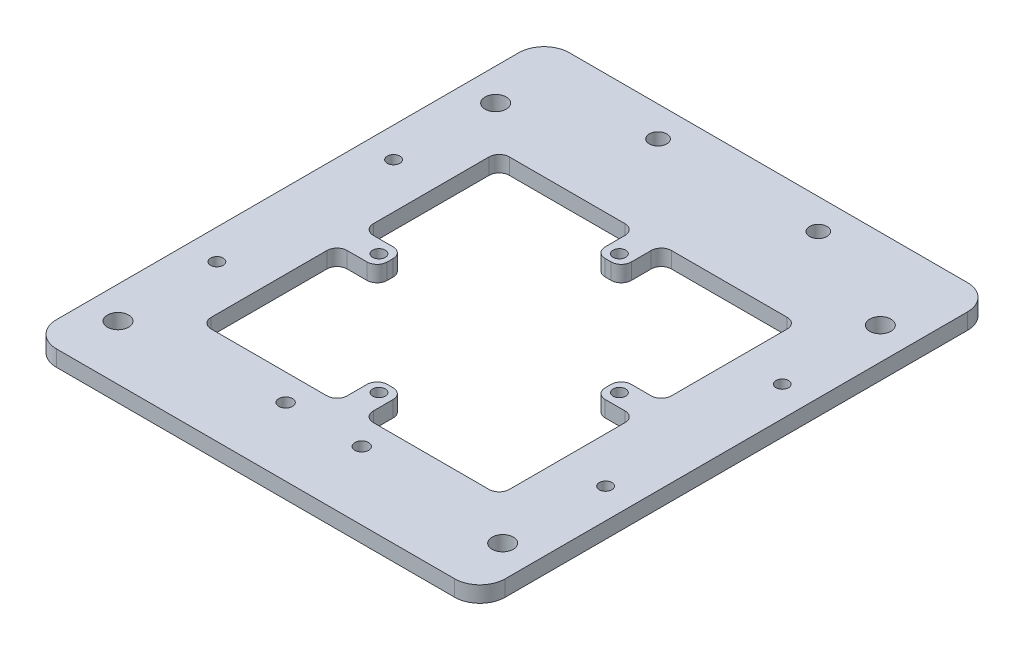
from build123d import *

# Parameters (mm, degrees)
ALUMINUM_PLATE_DEPTH            = 3.175
LPATTERN1_COUNT                 = 2
LPATTERN1_PITCH                 = 35
LPATTERN1_COUNT_DIR2            = 2
LPATTERN1_PITCH_DIR2            = 77
CIRPATTERN1_COUNT               = 4
TAP_DRILL_FOR_M5X0_8_TAP1_D     = 4.2
TAP_DRILL_FOR_M5X0_8_TAP1_DEPTH = 25.4
TAP_DRILL_FOR_M5X0_8_TAP1_TIP   = 1.2618073
TAP_DRILL_FOR_8_32_TAP1_D       = 3.4544
TAP_DRILL_FOR_8_32_TAP1_DEPTH   = 12.7
TAP_DRILL_FOR_8_32_TAP1_TIP     = 1.037806461
CUT_EXTRUDE1_REACH              = 96.743
CIRPATTERN3_COUNT               = 4
TAP_DRILL_FOR_6_32_TAP1_D       = 2.7051
TAP_DRILL_FOR_6_32_TAP1_DEPTH   = 12.7
TAP_DRILL_FOR_6_32_TAP1_TIP     = 0.81269403


with BuildPart() as part:
    # Sketch2 → Aluminum plate (new body)
    with BuildSketch(Plane(origin=(0, 0, 0), x_dir=(1, 0, 0), z_dir=(0, 1, 0))):
        with BuildLine():
            Line((58.024404898, -30.931736602), (-20.876528813, -30.930973959))
            ThreePointArc((-20.876528813, -30.930973959), (-24.412048563, -29.466473691), (-25.876480484, -25.93092563))
            Line((-25.876480484, -25.93092563), (-25.875595093, 65.669074365))
            ThreePointArc((-25.875595093, 65.669074365), (-24.411094826, 69.204594116), (-20.875546764, 70.669026036))
            Line((-20.875546764, 70.669026036), (58.024501561, 70.668263401))
            ThreePointArc((58.024501561, 70.668263401), (61.560004224, 69.20378022), (63.024453231, 65.668263401))
            Line((63.024453231, 65.668263401), (63.024453227, -25.931736603))
            ThreePointArc((63.024453227, -25.931736603), (61.559970046, -29.467287596), (58.024404898, -30.931736602))
        make_face()
        Polygon((40.164453228, -4.2611466), (-3.015546772, -4.261146598), (-3.01554677, 38.918853402), (40.16445323, 38.9188534), align=None, mode=Mode.SUBTRACT)
    extrude(amount=ALUMINUM_PLATE_DEPTH)

    # Sketch12 → Tap Drill for M3x0.5 Tap1 (revolve, cut)
    with BuildSketch(Plane(origin=(-19.925892409, 3.175, -34.909619628), x_dir=(0, 0, 1), z_dir=(1, 0, 0))):
        Polygon((0, 0), (0, 26.151075774), (1.25, 25.4), (1.25, 0), align=None)
    tap_drill_for_m3x0_5_tap1 = revolve(axis=Axis((-19.925892409, 9.525, -34.909619628), (0, -1, 0)), mode=Mode.SUBTRACT)

    # LPattern1: Tap Drill for M3x0.5 Tap1 2 × 2
    with Locations(*[(j * LPATTERN1_PITCH_DIR2, 0, i * LPATTERN1_PITCH) for i in range(LPATTERN1_COUNT) for j in range(LPATTERN1_COUNT_DIR2) if (i, j) != (0, 0)]):
        add(tap_drill_for_m3x0_5_tap1, mode=Mode.SUBTRACT)

    # Sketch14 → Tap Drill for M3x0.5 Tap2 (revolve, cut)
    with BuildSketch(Plane(origin=(42.384453228, 3.175, -17.329161252), x_dir=(0, 0, 1), z_dir=(1, 0, 0))):
        Polygon((0, 0), (0, 26.151075774), (1.25, 25.4), (1.25, 0), align=None)
    tap_drill_for_m3x0_5_tap2 = revolve(axis=Axis((42.384453228, 9.525, -17.329161252), (0, -1, 0)), mode=Mode.SUBTRACT)

    # CirPattern1: Tap Drill for M3x0.5 Tap2 ×4 about axis
    cirpattern1_axis = Axis((18.574453229, 62.671328425, -17.328853401), (0, -1, 0))
    for i in range(1, CIRPATTERN1_COUNT):
        add(tap_drill_for_m3x0_5_tap2.rotate(cirpattern1_axis, i * 360 / CIRPATTERN1_COUNT), mode=Mode.SUBTRACT)

    # Tap Drill for M5x0.8 Tap1
    with Locations(Plane.XZ):
        with Locations((-19.525700823, -54.730512991), (56.674299173, -54.729776455), (56.67357614, 20.073223545), (-19.526423857, 20.072487009)):
            Hole(TAP_DRILL_FOR_M5X0_8_TAP1_D / 2, depth=TAP_DRILL_FOR_M5X0_8_TAP1_DEPTH)
            with Locations((0, 0, -(TAP_DRILL_FOR_M5X0_8_TAP1_DEPTH + TAP_DRILL_FOR_M5X0_8_TAP1_TIP / 2))):  # 118° drill point
                Cone(0, TAP_DRILL_FOR_M5X0_8_TAP1_D / 2, TAP_DRILL_FOR_M5X0_8_TAP1_TIP, mode=Mode.SUBTRACT)

    # Tap Drill for _8-32 Tap1
    with Locations(Plane(origin=(0, 3.175, 0), x_dir=(-1, 0, 0), z_dir=(0, 1, 0))):
        with Locations((-2.699395239, -64.668798164), (-34.449395238, -64.668491274)):
            Hole(TAP_DRILL_FOR_8_32_TAP1_D / 2, depth=TAP_DRILL_FOR_8_32_TAP1_DEPTH)
            with Locations((0, 0, -(TAP_DRILL_FOR_8_32_TAP1_DEPTH + TAP_DRILL_FOR_8_32_TAP1_TIP / 2))):  # 118° drill point
                Cone(0, TAP_DRILL_FOR_8_32_TAP1_D / 2, TAP_DRILL_FOR_8_32_TAP1_TIP, mode=Mode.SUBTRACT)

    # Sketch24 → Cut-Extrude1 (cut, up to next)
    with BuildSketch(Plane(origin=(0, 3.175, 0), x_dir=(1, 0, 0), z_dir=(0, 1, 0)), mode=Mode.PRIVATE) as cut_extrude1_sk1:
        with BuildLine():
            Line((21.16445323, 40.9188534), (21.16445323, 44.8563534))
            ThreePointArc((21.16445323, 44.8563534), (21.750239668, 46.270566962), (23.16445323, 46.8563534))
            Line((23.16445323, 46.8563534), (46.101953228, 46.8563534))
            ThreePointArc((46.101953228, 46.8563534), (47.516166791, 46.270566962), (48.101953228, 44.8563534))
            Line((48.101953228, 44.8563534), (48.101953228, 21.9188534))
            ThreePointArc((48.101953228, 21.9188534), (47.516166791, 20.504639837), (46.101953228, 19.9188534))
            Line((46.101953228, 19.9188534), (42.164453228, 19.9188534))
            ThreePointArc((42.164453228, 19.9188534), (40.750239666, 19.333066962), (40.164453228, 17.9188534))
            Line((40.164453228, 17.9188534), (40.164453228, 17.3288534))
            Line((40.164453228, 17.3288534), (18.57445323, 38.9188534))
            Line((18.57445323, 38.9188534), (19.16445323, 38.9188534))
            ThreePointArc((19.16445323, 38.9188534), (20.578666793, 39.504639837), (21.16445323, 40.9188534))
        make_face()
    cut_extrude1_tool1 = extrude(cut_extrude1_sk1.sketch, amount=-CUT_EXTRUDE1_REACH, mode=Mode.PRIVATE) & part.part
    cut_extrude1 = cut_extrude1_tool1.solids().sort_by_distance((36.353241, 3.175, -35.107642))[0]
    add(cut_extrude1, mode=Mode.SUBTRACT)

    # CirPattern3: Cut-Extrude1 ×4 about axis
    cirpattern3_axis = Axis((18.574453229, 62.671328425, -17.328853401), (0, -1, 0))
    for i in range(1, CIRPATTERN3_COUNT):
        add(cut_extrude1.rotate(cirpattern3_axis, i * 360 / CIRPATTERN3_COUNT), mode=Mode.SUBTRACT)

    # Tap Drill for _6-32 Tap1
    with Locations(Plane(origin=(0, 3.175, 0), x_dir=(-1, 0, 0), z_dir=(0, 1, 0))):
        with Locations((-11.032976674, 17.431282391), (-26.114226674, 17.431282391)):
            Hole(TAP_DRILL_FOR_6_32_TAP1_D / 2, depth=TAP_DRILL_FOR_6_32_TAP1_DEPTH)
            with Locations((0, 0, -(TAP_DRILL_FOR_6_32_TAP1_DEPTH + TAP_DRILL_FOR_6_32_TAP1_TIP / 2))):  # 118° drill point
                Cone(0, TAP_DRILL_FOR_6_32_TAP1_D / 2, TAP_DRILL_FOR_6_32_TAP1_TIP, mode=Mode.SUBTRACT)


solid = part.part
